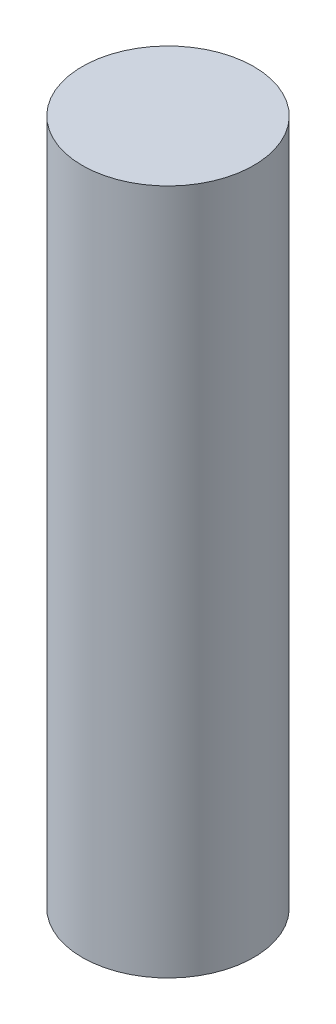
from build123d import *

# Parameters (mm, degrees)
SKETCH1_R           = 38.1
BOSS_EXTRUDE1_DEPTH = 304.8


with BuildPart() as part:
    # Sketch1 → Boss-Extrude1 (new body)
    with BuildSketch(Plane(origin=(0, 0, 0), x_dir=(1, 0, 0), z_dir=(0, 1, 0))):
        Circle(SKETCH1_R)
    extrude(amount=BOSS_EXTRUDE1_DEPTH)


solid = part.part
